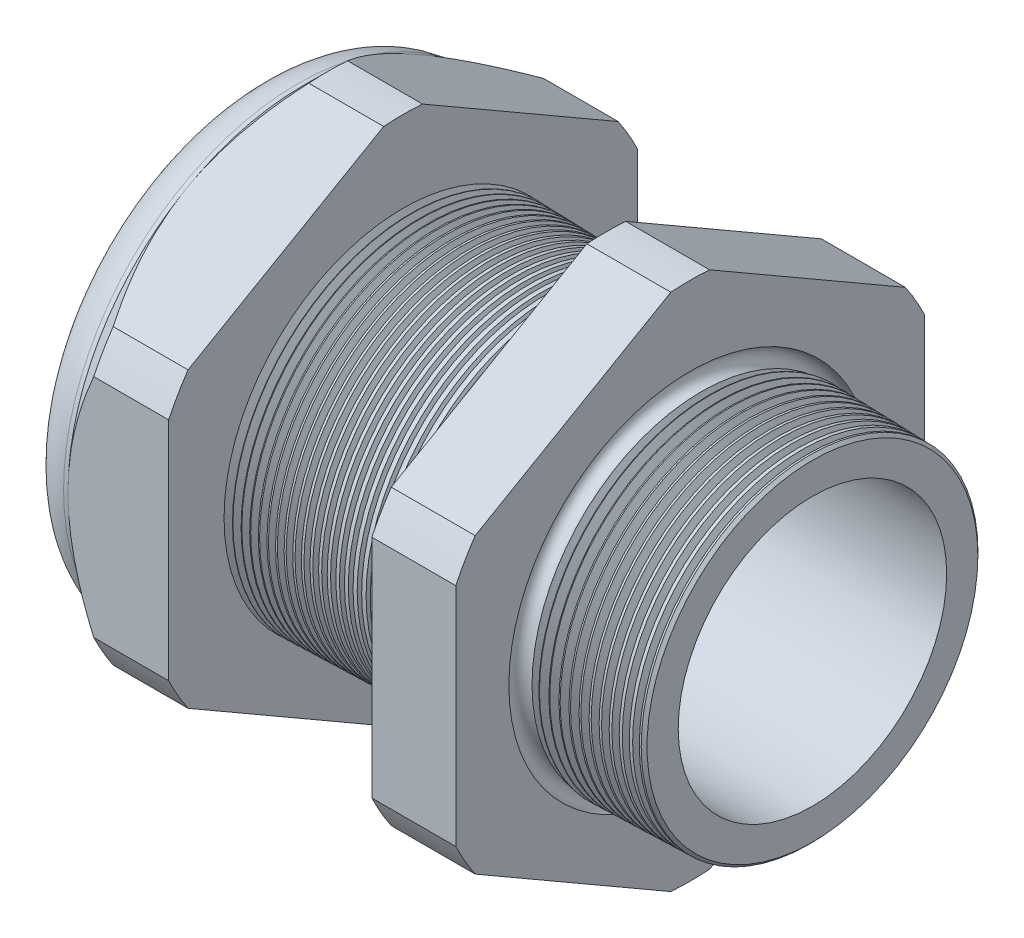
from build123d import *

# Parameters (mm, degrees)
SKETCH12_OUTSIDE_W = 111.534
SKETCH12_OUTSIDE_H = 111.534
CUT_EXTRUDE2_DEPTH = 46.584
FILLET4_R          = 3.81
SKETCH19_OUTSIDE_W = 67.904
SKETCH19_OUTSIDE_H = 72.514
SKETCH19_OUTSIDE_R = 20.955
CUT_EXTRUDE3_DEPTH = 3.99796
CUT_EXTRUDE3_DRAFT = -45
CHAMFER1_SIZE      = 0.260919487
CHAMFER1_SIZE2     = 0.254
SKETCH21_R         = 12.446
PLUG_DEPTH         = 12.7
SKETCH22_R         = 12.192
CUT_EXTRUDE4_DEPTH = 0.508
SKETCH27_R         = 4.445
PLUGHOLES_DEPTH    = 50.276
CIRPATTERN1_COUNT  = 4
LPATTERN1_COUNT    = 24
LPATTERN1_PITCH    = 0.762
LPATTERN2_COUNT    = 12
LPATTERN2_PITCH    = 0.889
SKETCH32_R         = 0.889


with BuildPart() as part:
    # Sketch10 → Revolve2 (revolve)
    with BuildSketch(Plane.XY, mode=Mode.PRIVATE) as revolve2_sk:
        Polygon((-46.736, 12.446), (-33.536, 12.446), (3.048, 11.996014245), (3.048, 15.044014245), (-7.874, 15.330016881), (-7.874, 41.91), (-15.374, 41.91), (-15.374, 15.526411292), (-33.536, 16.002), (-33.536, 41.91), (-42.536, 41.91), (-42.536, 20.955), (-46.736, 20.955), align=None)
    revolve(revolve2_sk.sketch.rotate(Axis((0, 0, 0), (-1, 0, 0)), 90), axis=Axis((0, 0, 0), (-1, 0, 0)))  # turned: the seam where the file's is

    # Sketch12 outside → Cut-Extrude2 (cut, through all)
    with BuildSketch(Plane.ZY.offset(42.536)):
        Rectangle(SKETCH12_OUTSIDE_W, SKETCH12_OUTSIDE_H)
        with BuildLine():
            Line((-1.734592832, 23.195282143), (-19.220407168, 13.099842529))
            ThreePointArc((-19.220407168, 13.099842529), (-20.143794193, 11.630025), (-20.955, 10.095439614))
            Line((-20.955, 10.095439614), (-20.955, -10.095439614))
            ThreePointArc((-20.955, -10.095439614), (-20.143794193, -11.630025), (-19.220407168, -13.099842529))
            Line((-19.220407168, -13.099842529), (-1.734592832, -23.195282143))
            ThreePointArc((-1.734592832, -23.195282143), (0, -23.26005), (1.734592832, -23.195282143))
            Line((1.734592832, -23.195282143), (19.220407168, -13.099842529))
            ThreePointArc((19.220407168, -13.099842529), (20.143794193, -11.630025), (20.955, -10.095439614))
            Line((20.955, -10.095439614), (20.955, 10.095439614))
            ThreePointArc((20.955, 10.095439614), (20.143794193, 11.630025), (19.220407168, 13.099842529))
            Line((19.220407168, 13.099842529), (1.734592832, 23.195282143))
            ThreePointArc((1.734592832, 23.195282143), (0, 23.26005), (-1.734592832, 23.195282143))
        make_face(mode=Mode.SUBTRACT)
    extrude(amount=-CUT_EXTRUDE2_DEPTH, mode=Mode.SUBTRACT)

    # Fillet4
    fillet4_edges = [part.edges().sort_by_distance(p)[0] for p in [
        (-46.736, 0, 20.955),
    ]]
    fillet(fillet4_edges, radius=FILLET4_R)


with BuildPart() as cut_extrude3_tool:
    # Sketch19 outside → Cut-Extrude3 (with draft: the straight prism first)
    with BuildSketch(Plane.ZY.offset(42.536)):
        Rectangle(SKETCH19_OUTSIDE_W, SKETCH19_OUTSIDE_H)
        Circle(SKETCH19_OUTSIDE_R, mode=Mode.SUBTRACT)
    extrude(amount=-CUT_EXTRUDE3_DEPTH)
    # Cut-Extrude3: the draft: its side faces are tilted about the plane it starts from
    cut_extrude3_sides = [cut_extrude3_tool.faces().sort_by_distance(p)[0] for p in [
        (-40.53702, -36.257, 0),
        (-40.53702, 0, 33.952),
        (-40.53702, 36.257, 0),
        (-40.53702, 0, -33.952),
        (-40.53702, 0, -20.955),
    ]]
    draft(cut_extrude3_sides, Plane.ZY.offset(42.536), CUT_EXTRUDE3_DRAFT)


with BuildPart() as part_1:
    add(part.part)

    # Cut-Extrude3: cut by cut_extrude3_tool
    add(cut_extrude3_tool.part, mode=Mode.SUBTRACT)

    # Chamfer1
    chamfer1_edges = [part_1.edges().sort_by_distance(p)[0] for p in [
        (3.048, 0, 15.044014245),
    ]]
    chamfer1_side = [part_1.faces().sort_by_distance(p)[0] for p in [
        (3.048, 0, 12.421523225),
    ]]
    chamfer(chamfer1_edges, length=CHAMFER1_SIZE, length2=CHAMFER1_SIZE2, reference=chamfer1_side[0])

    # Sketch29 → Cut-Revolve1 (revolve, cut)
    with BuildSketch(Plane.XY, mode=Mode.PRIVATE) as cut_revolve1_sk:
        Polygon((-33.536, 16.002), (-32.803016419, 15.982806149), (-33.186130572, 15.357620673), align=None)
    cut_revolve1 = revolve(cut_revolve1_sk.sketch.rotate(Axis((0, 0, 0), (-1, 0, 0)), 90), axis=Axis((0, 0, 0), (-1, 0, 0)), mode=Mode.SUBTRACT)  # turned: the seam where the file's is

    # LPattern1: Cut-Revolve1 ×24
    with Locations(*[(i * LPATTERN1_PITCH, 0, 0) for i in range(1, LPATTERN1_COUNT)]):
        add(cut_revolve1, mode=Mode.SUBTRACT)

    # Sketch30 → Cut-Revolve2 (revolve, cut)
    with BuildSketch(Plane.XY, mode=Mode.PRIVATE) as cut_revolve2_sk:
        Polygon((-7.874, 15.330016881), (-6.994419703, 15.30698426), (-7.454156686, 14.556761689), align=None)
    cut_revolve2 = revolve(cut_revolve2_sk.sketch.rotate(Axis((0, 0, 0), (-1, 0, 0)), 270), axis=Axis((0, 0, 0), (-1, 0, 0)), mode=Mode.SUBTRACT)  # turned: the seam where the file's is

    # LPattern2: Cut-Revolve2 ×12
    with Locations(*[(i * LPATTERN2_PITCH, 0, 0) for i in range(1, LPATTERN2_COUNT)]):
        add(cut_revolve2, mode=Mode.SUBTRACT)

    # Sketch32 → Cut-Revolve3 (revolve, cut)
    with BuildSketch(Plane.XY, mode=Mode.PRIVATE) as cut_revolve3_sk:
        with Locations((-7.747, 15.330016881)):
            Circle(SKETCH32_R)
    revolve(cut_revolve3_sk.sketch.rotate(Axis((0, 0, 0), (-1, 0, 0)), 270), axis=Axis((0, 0, 0), (-1, 0, 0)), mode=Mode.SUBTRACT)  # turned: the seam where the file's is


with BuildPart() as body_2:
    # Sketch21 → plug (new body)
    with BuildSketch(Plane.ZY.offset(46.736)):
        Circle(SKETCH21_R)
    extrude(amount=-PLUG_DEPTH)

    # Sketch22 → Cut-Extrude4 (cut)
    with BuildSketch(Plane.ZY.offset(46.736)):
        Circle(SKETCH22_R)
    extrude(amount=-CUT_EXTRUDE4_DEPTH, mode=Mode.SUBTRACT)

    # Sketch27 → plugholes (cut, through all)
    with BuildSketch(Plane.ZY.offset(46.228)):
        with Locations((-7.72922, 0)):
            Circle(SKETCH27_R)
    plugholes = extrude(amount=-PLUGHOLES_DEPTH, mode=Mode.SUBTRACT)

    # CirPattern1: plugholes ×4 about axis
    cirpattern1_axis = Axis((0, 0, 0), (1, 0, 0))
    for i in range(1, CIRPATTERN1_COUNT):
        add(plugholes.rotate(cirpattern1_axis, i * 360 / CIRPATTERN1_COUNT), mode=Mode.SUBTRACT)


solid = Compound([part_1.part, body_2.part])
